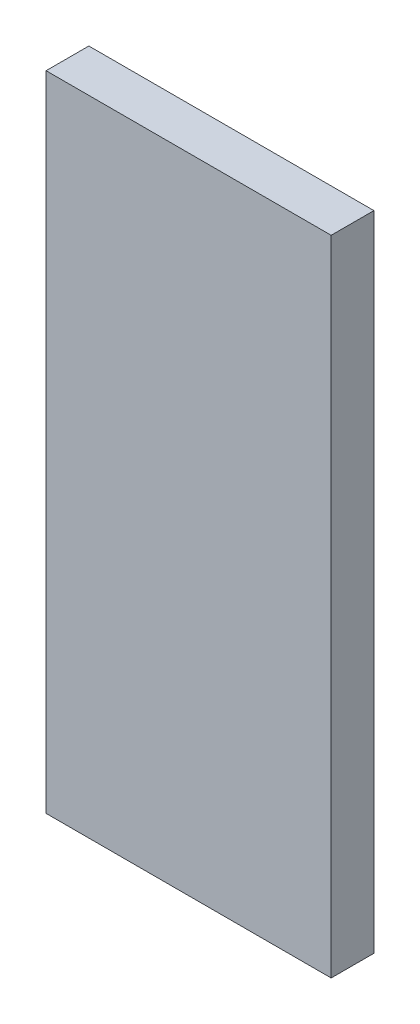
from build123d import *

# Parameters (mm, degrees)
CROQUIS1_W              = 80
CROQUIS1_H              = 180.5
SALIENTE_EXTRUIR1_DEPTH = 12


with BuildPart() as part:
    # Croquis1 → Saliente-Extruir1 (new body)
    with BuildSketch(Plane.XY):
        Rectangle(CROQUIS1_W, CROQUIS1_H)
    extrude(amount=SALIENTE_EXTRUIR1_DEPTH)


solid = part.part
